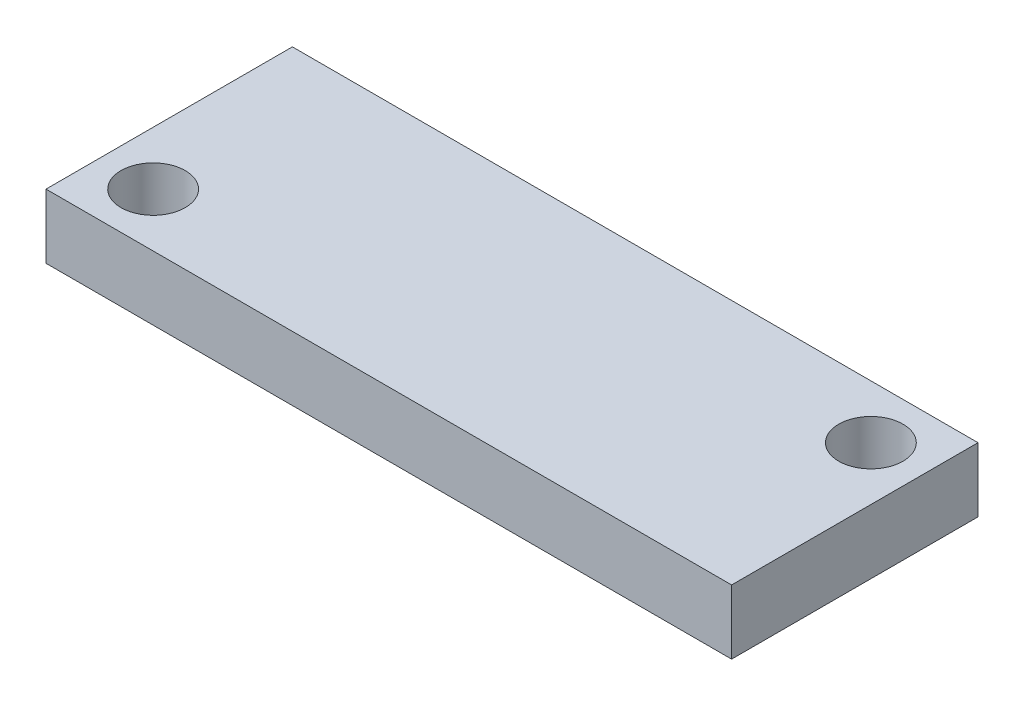
from build123d import *

# Parameters (mm, degrees)
SKETCH1_W           = 32
SKETCH1_H           = 11.5
SKETCH1_R           = 1.5
BOSS_EXTRUDE1_DEPTH = 3


with BuildPart() as part:
    # Sketch1 → Boss-Extrude1 (new body)
    with BuildSketch(Plane(origin=(0, 0, 0), x_dir=(1, 0, 0), z_dir=(0, 1, 0))):
        with Locations((16, 5.75)):
            Rectangle(SKETCH1_W, SKETCH1_H)
        with Locations((2.5, 2.5)):
            Circle(SKETCH1_R, mode=Mode.SUBTRACT)
        with Locations((29.5, 9)):
            Circle(SKETCH1_R, mode=Mode.SUBTRACT)
    extrude(amount=BOSS_EXTRUDE1_DEPTH)


solid = part.part
